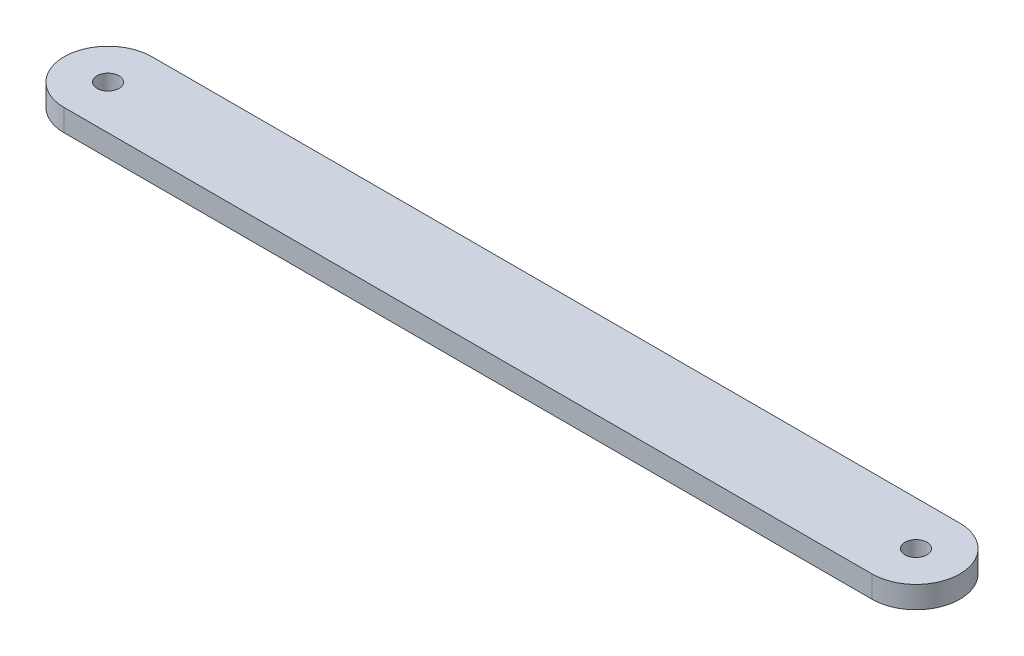
from build123d import *

# Parameters (mm, degrees)
SKETCH1_R           = 3.175
BOSS_EXTRUDE1_DEPTH = 6.35


with BuildPart() as part:
    # Sketch1 → Boss-Extrude1 (new body)
    with BuildSketch(Plane(origin=(0, 0, 0), x_dir=(1, 0, 0), z_dir=(0, 1, 0))):
        with BuildLine():
            Line((0, 12.7), (233.53, 12.7))
            ThreePointArc((233.53, 12.7), (246.23, 0), (233.53, -12.7))
            Line((233.53, -12.7), (0, -12.7))
            ThreePointArc((0, -12.7), (-12.7, 0), (0, 12.7))
        make_face()
        Circle(SKETCH1_R, mode=Mode.SUBTRACT)
        with Locations((233.53, 0)):
            Circle(SKETCH1_R, mode=Mode.SUBTRACT)
    extrude(amount=BOSS_EXTRUDE1_DEPTH)


solid = part.part
